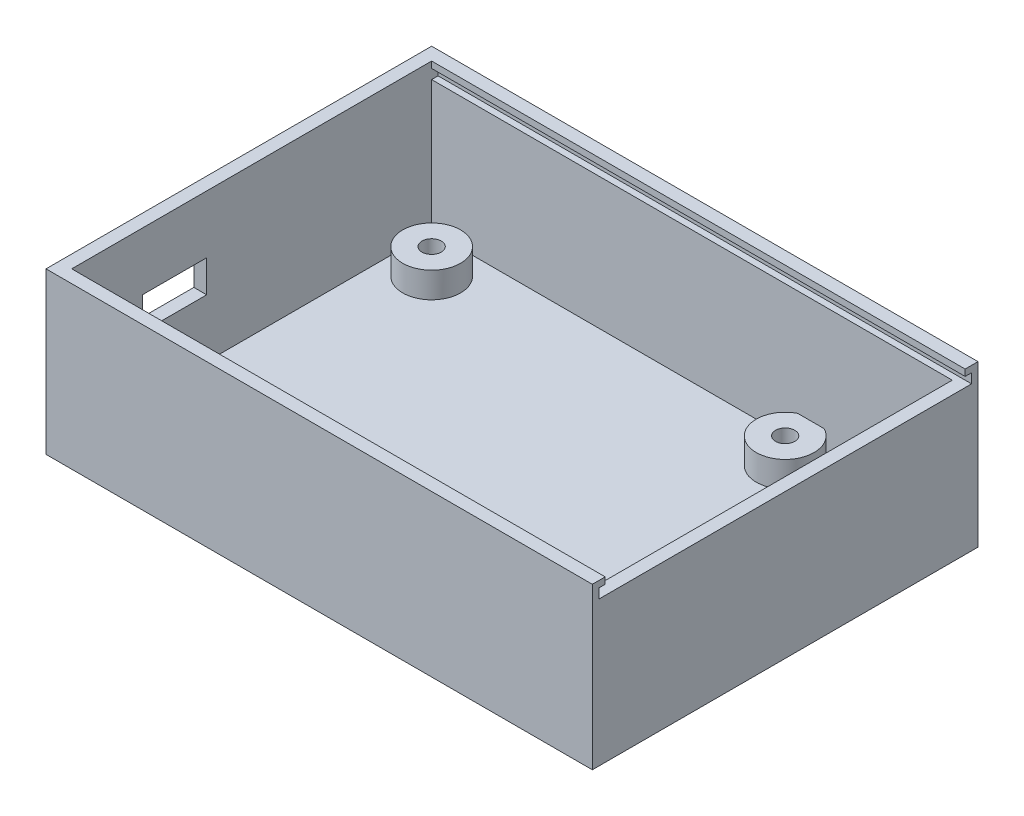
from build123d import *

# Parameters (mm, degrees)
SKIZZE1_W                       = 85
SKIZZE1_H                       = 60
AUFSATZ_LINEAR_AUSTRAGEN1_DEPTH = 25
WANDUNG1_T                      = -2
SKIZZE2_R                       = 4.5
SKIZZE2_R_2                     = 1.5
AUFSATZ_LINEAR_AUSTRAGEN2_DEPTH = 4
SCHNITT_LINEAR_AUSTRAGEN1_REACH = 87
SKIZZE3_W                       = 10
SKIZZE3_H                       = 5
SCHNITT_LINEAR_AUSTRAGEN2_REACH = 87
SKIZZE4_W                       = 56
SKIZZE4_H                       = 1
SKIZZE5_W                       = 58
SKIZZE5_H                       = 1.5
SCHNITT_LINEAR_AUSTRAGEN3_DEPTH = 83


with BuildPart() as part:
    # Skizze1 → Aufsatz-Linear austragen1 (new body)
    with BuildSketch(Plane(origin=(0, 0, 0), x_dir=(1, 0, 0), z_dir=(0, 1, 0))):
        with Locations((42.5, 30)):
            Rectangle(SKIZZE1_W, SKIZZE1_H)
    extrude(amount=AUFSATZ_LINEAR_AUSTRAGEN1_DEPTH)

    # Wandung1
    wandung1_openings = [part.faces().sort_by_distance(p)[0] for p in [
        (42.5, 25, -30),
    ]]
    offset(amount=WANDUNG1_T, openings=wandung1_openings, kind=Kind.INTERSECTION)

    # Skizze2 → Aufsatz-Linear austragen2 (add)
    with BuildSketch(Plane(origin=(0, 2, 0), x_dir=(1, 0, 0), z_dir=(0, 1, 0))):
        with Locations((8, 52)):
            Circle(SKIZZE2_R)
        with Locations((8, 52)):
            Circle(SKIZZE2_R_2, mode=Mode.SUBTRACT)
        with Locations((61, 54)):
            Circle(SKIZZE2_R)
        with Locations((61, 54)):
            Circle(SKIZZE2_R_2, mode=Mode.SUBTRACT)
        with Locations((68, 13)):
            Circle(SKIZZE2_R)
        with Locations((68, 13)):
            Circle(SKIZZE2_R_2, mode=Mode.SUBTRACT)
    extrude(amount=AUFSATZ_LINEAR_AUSTRAGEN2_DEPTH)

    # Skizze3 → Schnitt-Linear austragen1 (cut, up to next)
    with BuildSketch(Plane.ZY, mode=Mode.PRIVATE) as schnitt_linear_austragen1_sk1:
        with Locations((-18, 13.5)):
            Rectangle(SKIZZE3_W, SKIZZE3_H)
    schnitt_linear_austragen1_tool1 = extrude(schnitt_linear_austragen1_sk1.sketch, amount=-SCHNITT_LINEAR_AUSTRAGEN1_REACH, mode=Mode.PRIVATE) & part.part
    add(schnitt_linear_austragen1_tool1.solids().sort_by_distance((0, 13.5, -18))[0], mode=Mode.SUBTRACT)

    # Skizze4 → Schnitt-Linear austragen2 (cut, up to next)
    with BuildSketch(Plane(origin=(85, 0, 0), x_dir=(0, 0, -1), z_dir=(1, 0, 0)), mode=Mode.PRIVATE) as schnitt_linear_austragen2_sk1:
        with Locations((30, 24.5)):
            Rectangle(SKIZZE4_W, SKIZZE4_H)
    schnitt_linear_austragen2_tool1 = extrude(schnitt_linear_austragen2_sk1.sketch, amount=-SCHNITT_LINEAR_AUSTRAGEN2_REACH, mode=Mode.PRIVATE) & part.part
    add(schnitt_linear_austragen2_tool1.solids().sort_by_distance((85, 24.5, -30))[0], mode=Mode.SUBTRACT)

    # Skizze5 → Schnitt-Linear austragen3 (cut)
    with BuildSketch(Plane(origin=(85, 0, 0), x_dir=(0, 0, -1), z_dir=(1, 0, 0))):
        with Locations((30, 23.25)):
            Rectangle(SKIZZE5_W, SKIZZE5_H)
    extrude(amount=-SCHNITT_LINEAR_AUSTRAGEN3_DEPTH, mode=Mode.SUBTRACT)


solid = part.part
